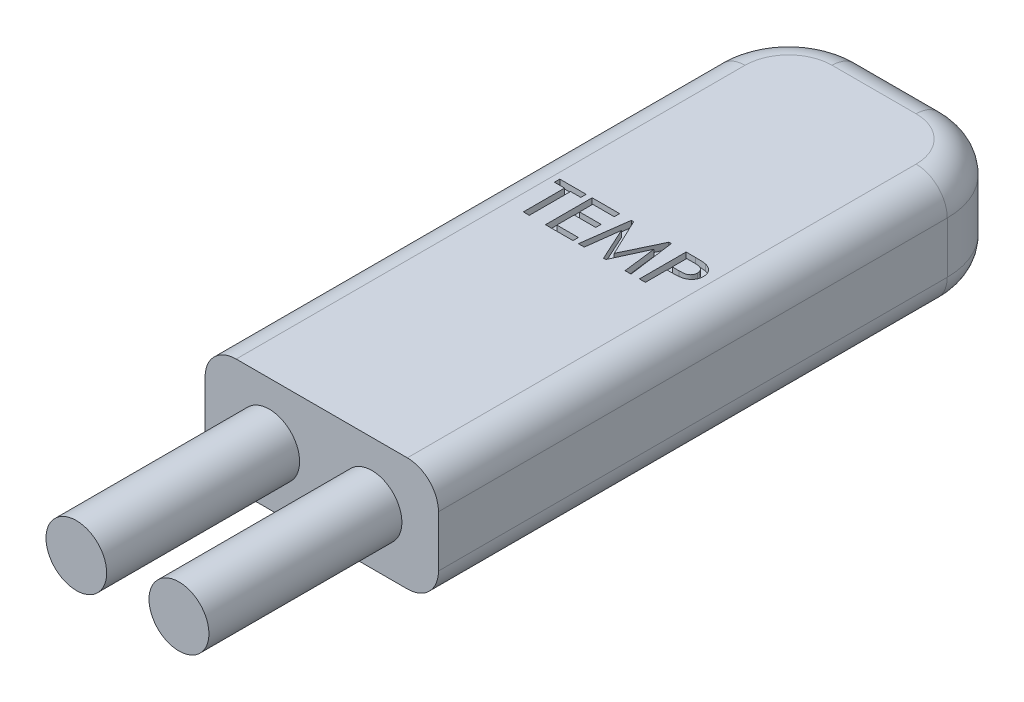
from build123d import *

# Parameters (mm, degrees)
SKETCH1_W           = 7.5
SKETCH1_H           = 18.75
BOSS_EXTRUDE1_DEPTH = 3.65
FILLET1_R           = 2.4
FILLET2_R           = 1
CUT_EXTRUDE1_DEPTH  = 0.2
SKETCH3_R           = 0.974780227
SKETCH3_R_2         = 0.962549202
BOSS_EXTRUDE2_DEPTH = 6.2


with BuildPart() as part:
    # Sketch1 → Boss-Extrude1 (new body)
    with BuildSketch(Plane(origin=(0, 0, 0), x_dir=(1, 0, 0), z_dir=(0, 1, 0))):
        with Locations((-16.912251656, 9.375)):
            Rectangle(SKETCH1_W, SKETCH1_H)
    extrude(amount=BOSS_EXTRUDE1_DEPTH)

    # Fillet1
    fillet1_edges = [part.edges().sort_by_distance(p)[0] for p in [
        (-20.662251656, 1.825, -18.75),
        (-13.162251656, 1.825, -18.75),
    ]]
    fillet(fillet1_edges, radius=FILLET1_R)

    # Fillet2
    fillet2_edges = [part.edges().sort_by_distance(p)[0] for p in [
        (-20.662251656, 0, -8.175),
        (-20.662251656, 3.65, -8.175),
        (-16.912251656, 0, -18.75),
        (-13.865195381, 0, -18.047056275),
        (-19.95930793, 0, -18.047056275),
        (-16.912251656, 3.65, -18.75),
        (-13.865195381, 3.65, -18.047056275),
        (-19.95930793, 3.65, -18.047056275),
        (-13.162251656, 3.65, -8.175),
        (-13.162251656, 0, -8.175),
    ]]
    fillet(fillet2_edges, radius=FILLET2_R)

    # Sketch2 → Cut-Extrude1 (cut)
    with BuildSketch(Plane(origin=(0, 3.65, 0), x_dir=(1, 0, 0), z_dir=(0, 1, 0))):
        Polygon((-19.47000828, 10.03416357), (-19.47000828, 10.207240493), (-18.623854434, 10.207240493), (-18.623854434, 10.03416357), (-18.950777511, 10.03416357), (-18.950777511, 8.707240493), (-19.143085203, 8.707240493), (-19.143085203, 10.03416357), align=None)
        Polygon((-18.431546742, 10.207240493), (-17.546931357, 10.207240493), (-17.546931357, 10.03416357), (-18.239239049, 10.03416357), (-18.239239049, 9.611086647), (-17.546931357, 9.611086647), (-17.546931357, 9.438009724), (-18.239239049, 9.438009724), (-18.239239049, 8.880317416), (-17.546931357, 8.880317416), (-17.546931357, 8.707240493), (-18.431546742, 8.707240493), align=None)
        Polygon((-17.373854434, 8.707240493), (-17.173433761, 10.207240493), (-17.097712607, 10.207240493), (-16.528902511, 9.014932801), (-15.960092415, 10.207240493), (-15.883169338, 10.207240493), (-15.681546742, 8.707240493), (-15.87235203, 8.707240493), (-16.005765492, 9.764932801), (-16.492544338, 8.707240493), (-16.565260684, 8.707240493), (-17.050537126, 9.764932801), (-17.183349626, 8.707240493), align=None)
        with BuildLine():
            Line((-15.412315972, 10.207240493), (-15.104924145, 10.207240493))
            add(Edge.make_bspline(
                [(-15.104924145, 10.207240493), (-15.084590431, 10.207229415), (-15.045621744, 10.207208186), (-14.989736478, 10.205769609), (-14.939035959, 10.204527998), (-14.893445271, 10.202141516), (-14.853068216, 10.198872492), (-14.817890297, 10.195028512), (-14.787873744, 10.190705096), (-14.769771411, 10.186796384), (-14.761474626, 10.185004916)],
                knots=[0, 0, 0, 0, 6.0998e-05, 0.000116901, 0.000167704, 0.00021314, 0.00025384, 0.000289212, 0.000319299, 0.000344757, 0.000344757, 0.000344757, 0.000344757], degree=3))
            add(Edge.make_bspline(
                [(-14.761474626, 10.185004916), (-14.749794935, 10.182001417), (-14.726754486, 10.176076436), (-14.693817305, 10.163863296), (-14.662564371, 10.14998558), (-14.633102385, 10.134199208), (-14.60573229, 10.115966796), (-14.579863591, 10.096157565), (-14.55629197, 10.073769594), (-14.534209882, 10.049888971), (-14.51483493, 10.023970245), (-14.497474918, 9.996890427), (-14.483086108, 9.96825619), (-14.47126094, 9.938174045), (-14.462016779, 9.906800832), (-14.455367321, 9.874036593), (-14.451371733, 9.839953174), (-14.450978032, 9.816726583), (-14.450777511, 9.804896743)],
                knots=[0, 0, 0, 0, 3.6158e-05, 7.1328e-05, 0.000105224, 0.000138702, 0.000171454, 0.00020379, 0.000236316, 0.000268858, 0.00030125, 0.000333261, 0.000365243, 0.000397216, 0.000430113, 0.000463231, 0.000497409, 0.000532886, 0.000532886, 0.000532886, 0.000532886], degree=3))
            add(Edge.make_bspline(
                [(-14.450777511, 9.804896743), (-14.450982431, 9.793067454), (-14.451386495, 9.769742405), (-14.455356851, 9.735455231), (-14.462012335, 9.702622928), (-14.470985169, 9.671100454), (-14.482777462, 9.641083852), (-14.496868277, 9.612319712), (-14.513901371, 9.585133925), (-14.533346655, 9.559337792), (-14.55530593, 9.535327744), (-14.579460944, 9.513194915), (-14.606129209, 9.493325844), (-14.635037209, 9.475363904), (-14.666084216, 9.458994121), (-14.699582563, 9.444914312), (-14.735382799, 9.432916973), (-14.76022897, 9.426537659), (-14.772892895, 9.423286166)],
                knots=[0, 0, 0, 0, 3.5477e-05, 6.9954e-05, 0.000103367, 0.000135891, 0.000168143, 0.000199991, 0.000231842, 0.000264234, 0.000296777, 0.000329319, 0.000362372, 0.000396389, 0.000431334, 0.000467554, 0.000505277, 0.000544492, 0.000544492, 0.000544492, 0.000544492], degree=3))
            add(Edge.make_bspline(
                [(-14.772892895, 9.423286166), (-14.782187231, 9.421271087), (-14.802462631, 9.416875234), (-14.836108437, 9.412301035), (-14.875312671, 9.40855358), (-14.920199238, 9.405293226), (-14.970584149, 9.402554499), (-15.026690891, 9.4009242), (-15.0883915, 9.39960867), (-15.13146575, 9.3995689), (-15.153902511, 9.399548185)],
                knots=[0, 0, 0, 0, 2.8522e-05, 6.222e-05, 0.000101776, 0.00014667, 0.000197223, 0.000253141, 0.000315052, 0.000382361, 0.000382361, 0.000382361, 0.000382361], degree=3))
            Line((-15.153902511, 9.399548185), (-15.22000828, 9.399548185))
            Line((-15.22000828, 9.399548185), (-15.22000828, 8.707240493))
            Line((-15.22000828, 8.707240493), (-15.412315972, 8.707240493))
            Line((-15.412315972, 8.707240493), (-15.412315972, 10.207240493))
        make_face()
        with BuildLine():
            Line((-15.22000828, 10.03416357), (-15.22000828, 9.572024147))
            Line((-15.22000828, 9.572024147), (-15.003662126, 9.569620301))
            add(Edge.make_bspline(
                [(-15.003662126, 9.569620301), (-14.991442118, 9.569781438), (-14.96789801, 9.570091898), (-14.933922023, 9.571169852), (-14.90267133, 9.573360722), (-14.874085566, 9.575915893), (-14.848106984, 9.579498254), (-14.824852537, 9.583969214), (-14.804123942, 9.58899258), (-14.780420498, 9.596890423), (-14.753888196, 9.609222279), (-14.72568146, 9.628038142), (-14.700818195, 9.650540527), (-14.680284887, 9.67702579), (-14.663760532, 9.706207338), (-14.651477561, 9.737397026), (-14.644525179, 9.770537082), (-14.643569262, 9.793147018), (-14.643085203, 9.804596262)],
                knots=[0, 0, 0, 0, 3.6664e-05, 7.0639e-05, 0.00010196, 0.000130633, 0.000156725, 0.000180592, 0.000201654, 0.000220658, 0.000255475, 0.00028906, 0.000322027, 0.000355628, 0.000389134, 0.000422335, 0.000455809, 0.000490148, 0.000490148, 0.000490148, 0.000490148], degree=3))
            add(Edge.make_bspline(
                [(-14.643085203, 9.804596262), (-14.643572758, 9.815645957), (-14.644539806, 9.837562612), (-14.65152853, 9.869796434), (-14.663817169, 9.900371212), (-14.680368439, 9.929142837), (-14.700481342, 9.955440534), (-14.724306032, 9.978063055), (-14.751268987, 9.996551957), (-14.776440979, 10.008393772), (-14.798885683, 10.016100206), (-14.818667462, 10.020627198), (-14.841014829, 10.024859872), (-14.866066555, 10.028488465), (-14.893845944, 10.031105466), (-14.924319512, 10.03278413), (-14.957376784, 10.034099627), (-14.980323278, 10.034141709), (-14.992243857, 10.03416357)],
                knots=[0, 0, 0, 0, 3.314e-05, 6.5732e-05, 9.8374e-05, 0.000131619, 0.000165036, 0.000197343, 0.000229764, 0.000262694, 0.000280463, 0.000300869, 0.000323499, 0.000348698, 0.000376774, 0.000407176, 0.000440251, 0.000476009, 0.000476009, 0.000476009, 0.000476009], degree=3))
            Line((-14.992243857, 10.03416357), (-15.22000828, 10.03416357))
        make_face(mode=Mode.SUBTRACT)
    extrude(amount=-CUT_EXTRUDE1_DEPTH, mode=Mode.SUBTRACT)

    # Sketch3 → Boss-Extrude2 (add)
    with BuildSketch(Plane.XY):
        with Locations((-18.59951473, 1.812377858)):
            Circle(SKETCH3_R)
        with Locations((-15.301212194, 1.766139972)):
            Circle(SKETCH3_R_2)
    extrude(amount=BOSS_EXTRUDE2_DEPTH)


solid = part.part
